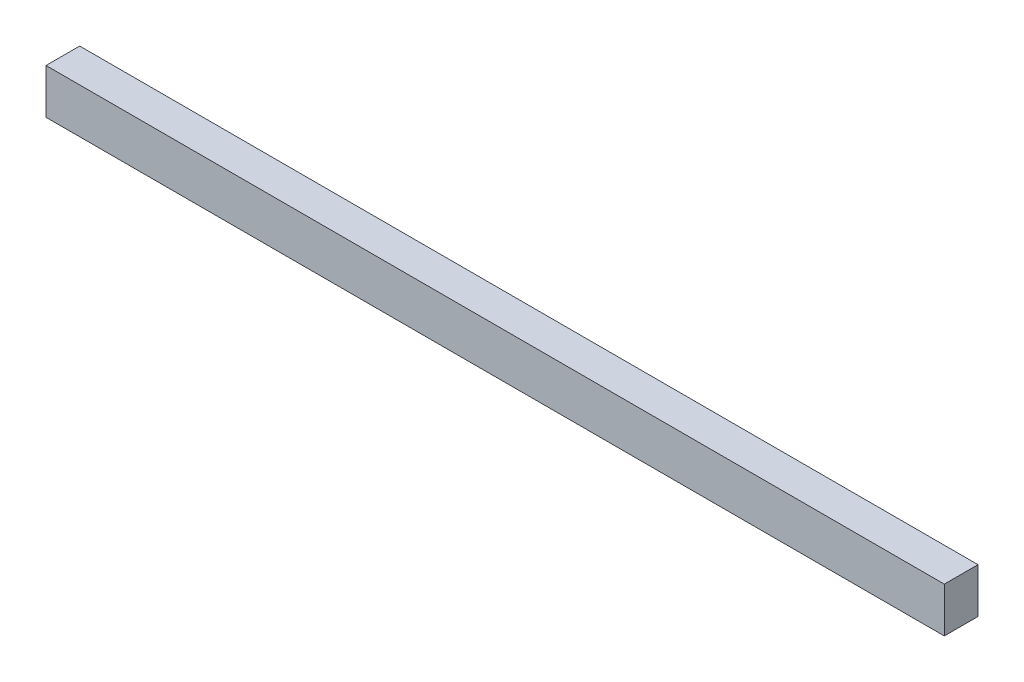
from build123d import *

# Parameters (mm, degrees)
SKETCH1_W           = 400
SKETCH1_H           = 20
BOSS_EXTRUDE1_DEPTH = 7.5
SKETCH2_R           = 4
CUT_EXTRUDE1_DEPTH  = 10


with BuildPart() as part:
    # Sketch1 → Boss-Extrude1 (new body, symmetric)
    with BuildSketch(Plane.XY):
        Rectangle(SKETCH1_W, SKETCH1_H)
    extrude(amount=BOSS_EXTRUDE1_DEPTH, both=True)

    # Sketch2 → Cut-Extrude1 (cut)
    with BuildSketch(Plane(origin=(0, 0, -7.5), x_dir=(-1, 0, 0), z_dir=(0, 0, -1))):
        with Locations((-192.5, 0)):
            Circle(SKETCH2_R)
    cut_extrude1 = extrude(amount=-CUT_EXTRUDE1_DEPTH, mode=Mode.SUBTRACT)

    # Mirror1: Cut-Extrude1 across plane
    add(cut_extrude1.mirror(Plane(origin=(0, 0, 0), x_dir=(0, 0, 1), z_dir=(1, 0, 0))), mode=Mode.SUBTRACT)


solid = part.part
